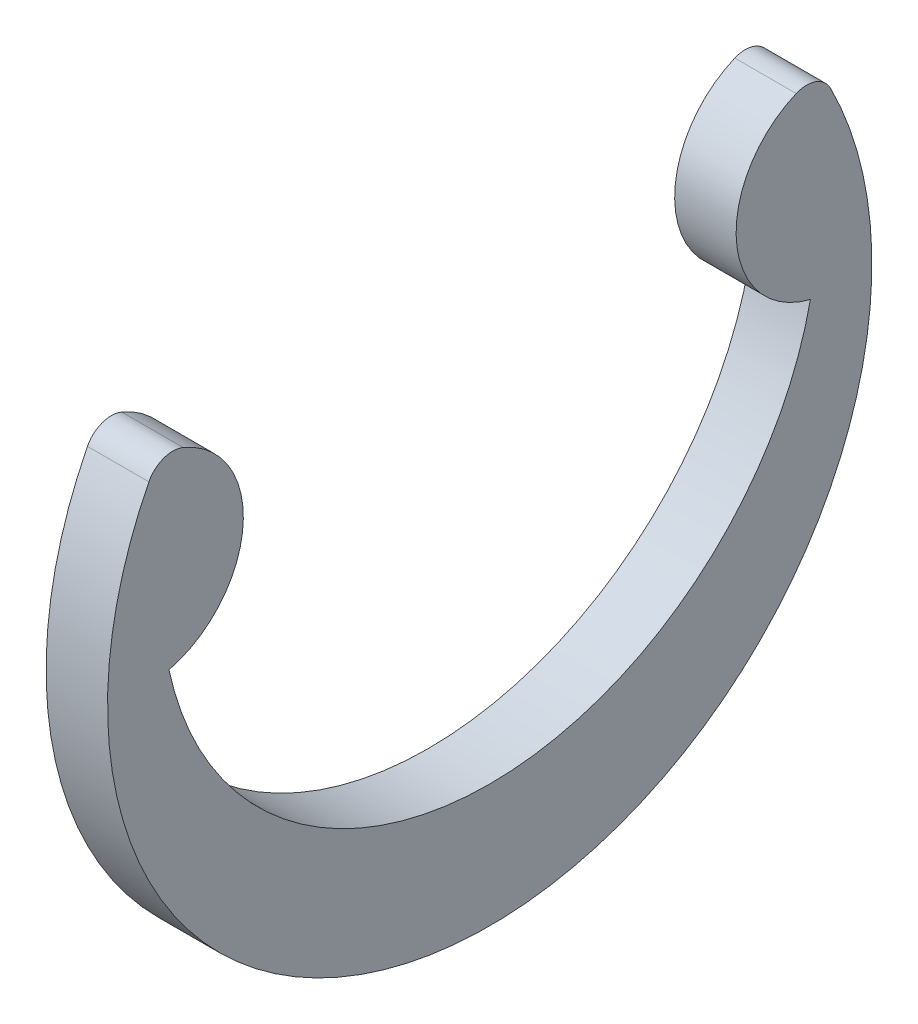
from build123d import *

# Parameters (mm, degrees)
EXTRUDE1_DEPTH = 0.3175


with BuildPart() as part:
    # Sketch1 → Extrude1 (new body, symmetric)
    with BuildSketch(Plane(origin=(0, 0, 0), x_dir=(0, 0, -1), z_dir=(1, 0, 0))):
        with BuildLine():
            ThreePointArc((-3.3147, 0), (0, -2.6797), (3.3147, 0))
            ThreePointArc((3.3147, 0), (2.549464409, 0.90546195), (3.16791514, 1.916879543))
            ThreePointArc((3.16791514, 1.916879543), (3.370887549, 1.921386385), (3.52259378, 1.786466667))
            ThreePointArc((3.52259378, 1.786466667), (0, -3.9497), (-3.52259378, 1.786466667))
            ThreePointArc((-3.52259378, 1.786466667), (-3.370887549, 1.921386385), (-3.16791514, 1.916879543))
            ThreePointArc((-3.16791514, 1.916879543), (-2.549464409, 0.90546195), (-3.3147, 0))
        make_face()
    extrude(amount=EXTRUDE1_DEPTH, both=True)


solid = part.part
